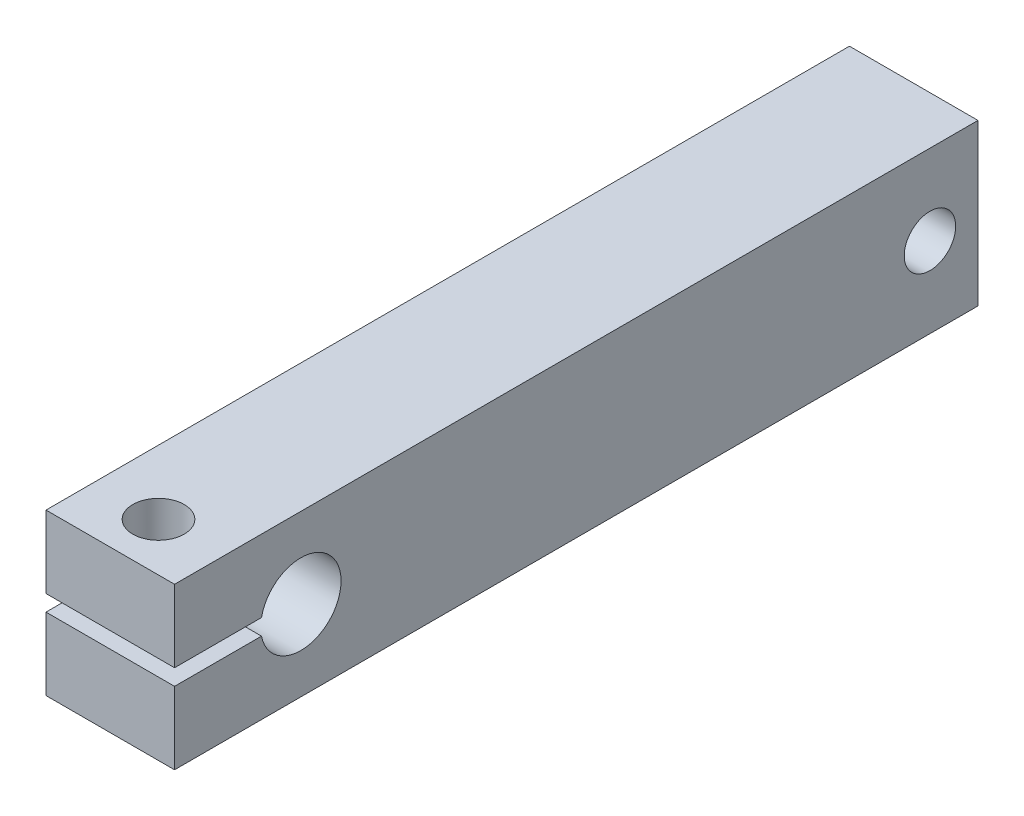
from build123d import *

# Parameters (mm, degrees)
SKETCH_1_W          = 8
SKETCH_1_H          = 10
EXTRUDE_1_DEPTH     = 40
SKETCH_5_W          = 8
SKETCH_5_H          = 10
EXTRUDE_2_DEPTH     = 10
SKETCH_7_R          = 1.6
CUT_EXTRUDE_4_DEPTH = 9
CUT_EXTRUDE_6_DEPTH = 9
SKETCH_3_R          = 1.6
CUT_EXTRUDE_7_DEPTH = 11


with BuildPart() as part:
    # 草图1 → 凸台-拉伸1 (new body)
    with BuildSketch(Plane.XY):
        with Locations((4, 5)):
            Rectangle(SKETCH_1_W, SKETCH_1_H)
    extrude(amount=EXTRUDE_1_DEPTH)

    # 草图5 → 凸台-拉伸2 (add)
    with BuildSketch(Plane(origin=(0, 0, 0), x_dir=(-1, 0, 0), z_dir=(0, 0, -1))):
        with Locations((-4, 5)):
            Rectangle(SKETCH_5_W, SKETCH_5_H)
    extrude(amount=EXTRUDE_2_DEPTH)

    # 草图7 → 切除-拉伸4 (cut, through all)
    with BuildSketch(Plane(origin=(8, 0, 0), x_dir=(0, 0, -1), z_dir=(1, 0, 0))):
        with Locations((7.0094551, 5)):
            Circle(SKETCH_7_R)
    extrude(amount=-CUT_EXTRUDE_4_DEPTH, mode=Mode.SUBTRACT)

    # 草图10 → 切除-拉伸6 (cut, through all)
    with BuildSketch(Plane.ZY):
        with BuildLine():
            Line((40, 5), (40, 5.5))
            Line((40, 5.5), (34.59, 5.5))
            ThreePointArc((34.59, 5.5), (29.63950005, 5), (34.59, 4.5))
            Line((34.59, 4.5), (40, 4.5))
            Line((40, 4.5), (40, 5))
        make_face()
    extrude(amount=-CUT_EXTRUDE_6_DEPTH, mode=Mode.SUBTRACT)

    # 草图3 → 切除-拉伸7 (cut, through all)
    with BuildSketch(Plane.XZ):
        with Locations((4, 37)):
            Circle(SKETCH_3_R)
    extrude(amount=-CUT_EXTRUDE_7_DEPTH, mode=Mode.SUBTRACT)


solid = part.part
